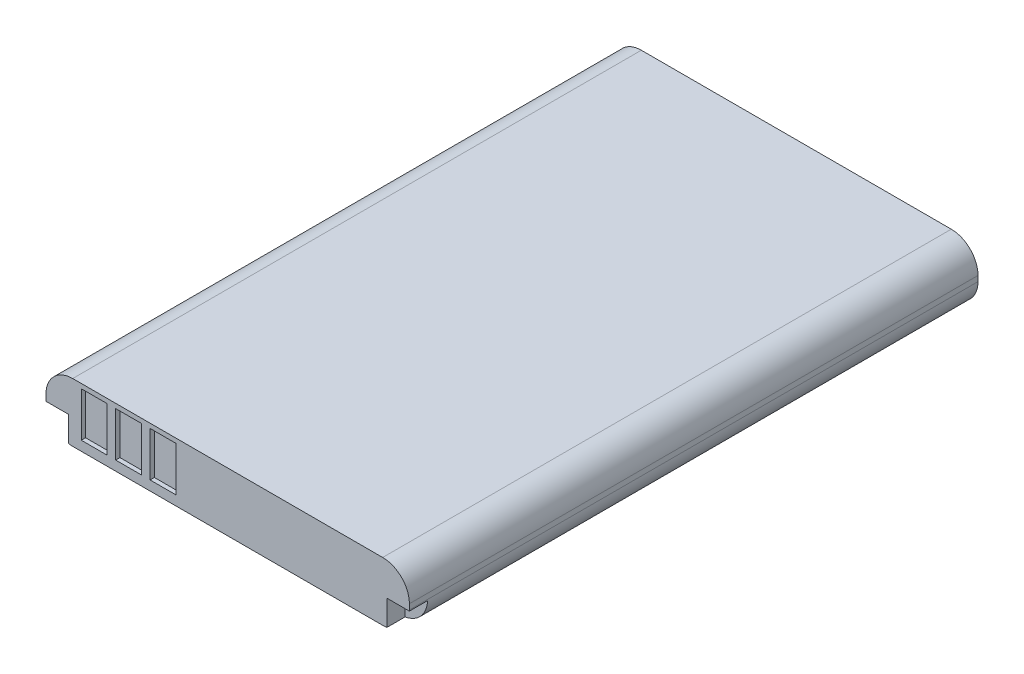
from build123d import *

# Parameters (mm, degrees)
SKETCH1_W           = 34
SKETCH1_H           = 53.2
BOSS_EXTRUDE1_DEPTH = 5.5
FILLET1_R           = 2.5
SKETCH2_W           = 2.4
SKETCH2_H           = 4.175
CUT_EXTRUDE1_DEPTH  = 0.4
LPATTERN1_COUNT     = 3
LPATTERN1_PITCH     = 3.22
SKETCH4_W           = 4.132195005
SKETCH4_H           = 2.4
CUT_EXTRUDE2_DEPTH  = 1.7
SKETCH5_W           = 19.8
SKETCH5_H           = 3.15
CUT_EXTRUDE3_DEPTH  = 0.1


with BuildPart() as part:
    # Sketch1 → Boss-Extrude1 (new body)
    with BuildSketch(Plane(origin=(0, 0, 0), x_dir=(1, 0, 0), z_dir=(0, 1, 0))):
        Rectangle(SKETCH1_W, SKETCH1_H)
    extrude(amount=BOSS_EXTRUDE1_DEPTH)

    # Fillet1
    fillet1_edges = [part.edges().sort_by_distance(p)[0] for p in [
        (-17, 0, 0),
        (-17, 5.5, 0),
        (17, 0, 0),
        (17, 5.5, 0),
    ]]
    fillet(fillet1_edges, radius=FILLET1_R)

    # Sketch2 → Cut-Extrude1 (cut)
    with BuildSketch(Plane.XY.offset(26.6)):
        with Locations((-12.5, 2.9875)):
            Rectangle(SKETCH2_W, SKETCH2_H)
    cut_extrude1 = extrude(amount=-CUT_EXTRUDE1_DEPTH, mode=Mode.SUBTRACT)

    # LPattern1: Cut-Extrude1 ×3
    with Locations(*[(i * LPATTERN1_PITCH, 0, 0) for i in range(1, LPATTERN1_COUNT)]):
        add(cut_extrude1, mode=Mode.SUBTRACT)

    # Sketch4 → Cut-Extrude2 (cut)
    with BuildSketch(Plane.XY.offset(26.6)):
        with Locations((-16.966097503, 1.2)):
            Rectangle(SKETCH4_W, SKETCH4_H)
    cut_extrude2 = extrude(amount=-CUT_EXTRUDE2_DEPTH, mode=Mode.SUBTRACT)

    # Mirror1: Cut-Extrude2 across plane
    add(cut_extrude2.mirror(Plane(origin=(0, 0, 0), x_dir=(0, 0, 1), z_dir=(1, 0, 0))), mode=Mode.SUBTRACT)

    # Sketch5 → Cut-Extrude3 (cut)
    with BuildSketch(Plane(origin=(0, 0, -26.6), x_dir=(-1, 0, 0), z_dir=(0, 0, -1))):
        with Locations((0, 2.75)):
            Rectangle(SKETCH5_W, SKETCH5_H)
    extrude(amount=-CUT_EXTRUDE3_DEPTH, mode=Mode.SUBTRACT)


solid = part.part
